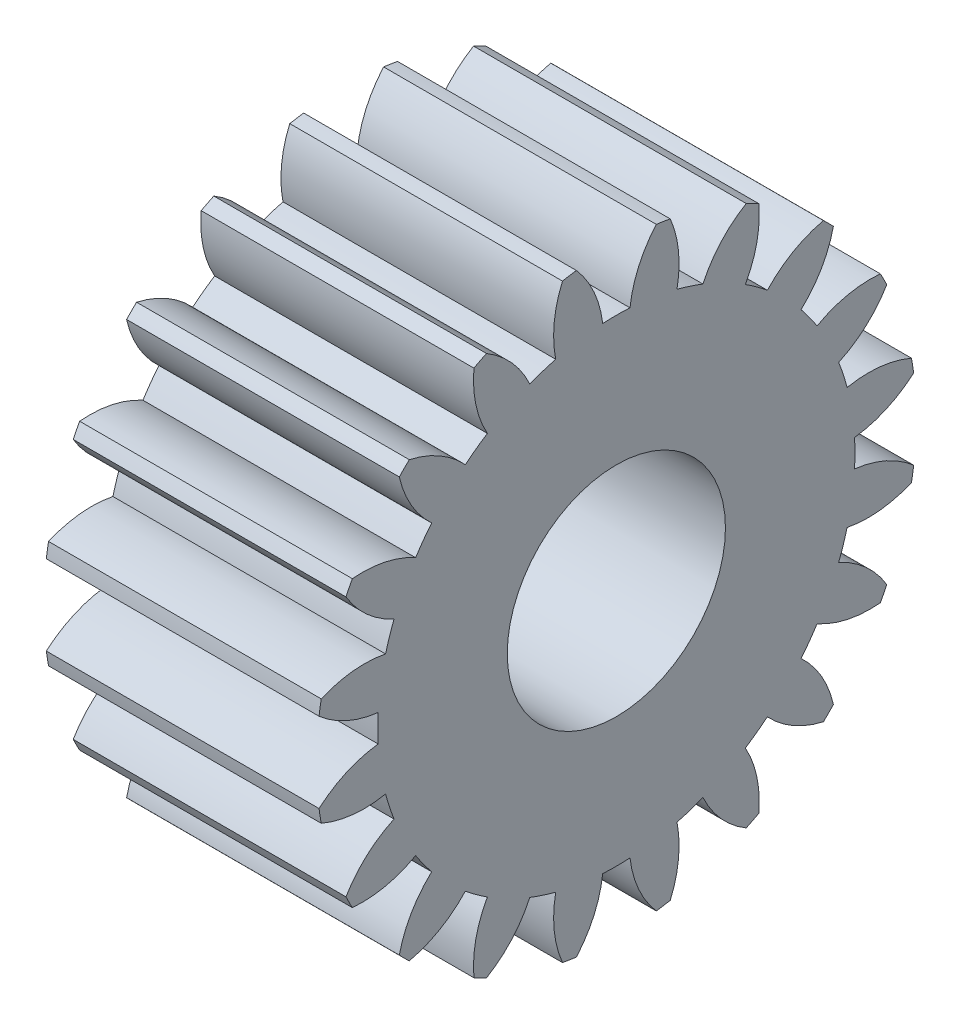
from build123d import *

# Parameters (mm, degrees)
BASPROSKE_W     = 10
BASPROSKE_H     = 11
TOOTHCUT_DEPTH  = 19.493242009
TEETHCUTS_COUNT = 20
TEETHCUTS_ANGLE = 342
BORSKE_R        = 4
BORE_DEPTH      = 50.0000508


with BuildPart() as part:
    # BasProSke → Base-Revolve (revolve)
    with BuildSketch(Plane(origin=(0, 0, 0), x_dir=(1, 0, 0), z_dir=(0, 1, 0)), mode=Mode.PRIVATE) as base_revolve_sk:
        with Locations((5, 5.5)):
            Rectangle(BASPROSKE_W, BASPROSKE_H)
    revolve(base_revolve_sk.sketch.rotate(Axis((-10, 0, 0), (1, 0, 0)), 180), axis=Axis((-10, 0, 0), (1, 0, 0)))

    # TooCutSke → ToothCut (cut, through all)
    with BuildSketch(Plane(origin=(0, 0, 0), x_dir=(0, 0, -1), z_dir=(1, 0, 0))):
        with BuildLine():
            ThreePointArc((0.499924007, 8.734705318), (0, 8.749), (-0.499924007, 8.734705318))
            ThreePointArc((-0.499924007, 8.734705318), (-0.824302243, 9.905497836), (-1.485192705, 10.924909509))
            ThreePointArc((-1.485192705, 10.924909509), (0, 11.0254), (1.485192705, 10.924909509))
            ThreePointArc((1.485192705, 10.924909509), (0.824302243, 9.905497836), (0.499924007, 8.734705318))
        make_face()
    toothcut = extrude(amount=TOOTHCUT_DEPTH, mode=Mode.SUBTRACT)

    # TeethCuts: ToothCut ×20 about axis
    teethcuts_axis = Axis((-10, 0, 0), (1, 0, 0))
    for i in range(1, TEETHCUTS_COUNT):
        add(toothcut.rotate(teethcuts_axis, i * TEETHCUTS_ANGLE / (TEETHCUTS_COUNT - 1)), mode=Mode.SUBTRACT)

    # BorSke → Bore (cut, symmetric)
    with BuildSketch(Plane(origin=(0, 0, 0), x_dir=(0, 0, -1), z_dir=(1, 0, 0))):
        with Locations(Location((0, 0, 0), (0, 0, 180))):
            Circle(BORSKE_R)
    extrude(amount=BORE_DEPTH, both=True, mode=Mode.SUBTRACT)


solid = part.part
